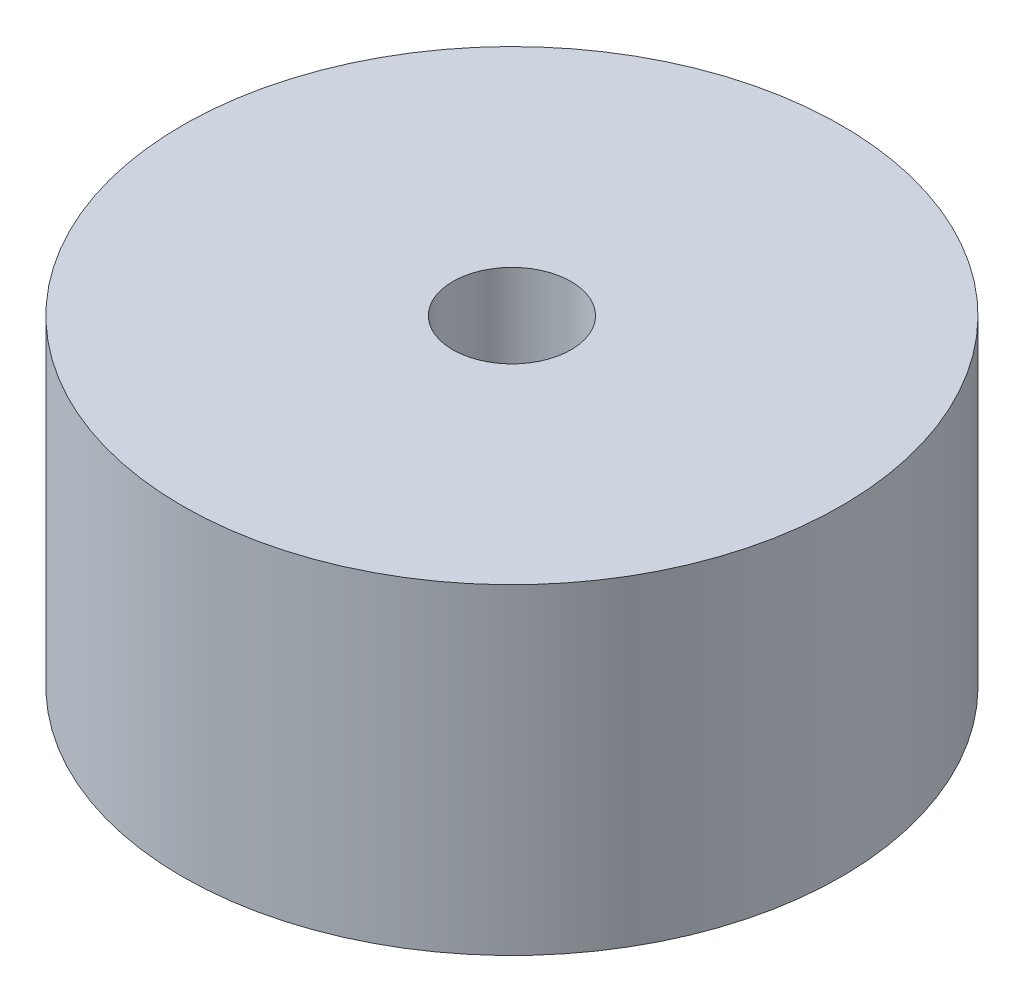
from build123d import *

# Parameters (mm, degrees)
SKETCH1_R           = 19.5
SKETCH1_R_2         = 3.5
BOSS_EXTRUDE1_DEPTH = 19


with BuildPart() as part:
    # Sketch1 → Boss-Extrude1 (new body)
    with BuildSketch(Plane(origin=(0, 0, 0), x_dir=(1, 0, 0), z_dir=(0, 1, 0))):
        Circle(SKETCH1_R)
        Circle(SKETCH1_R_2, mode=Mode.SUBTRACT)
    extrude(amount=BOSS_EXTRUDE1_DEPTH)


solid = part.part
